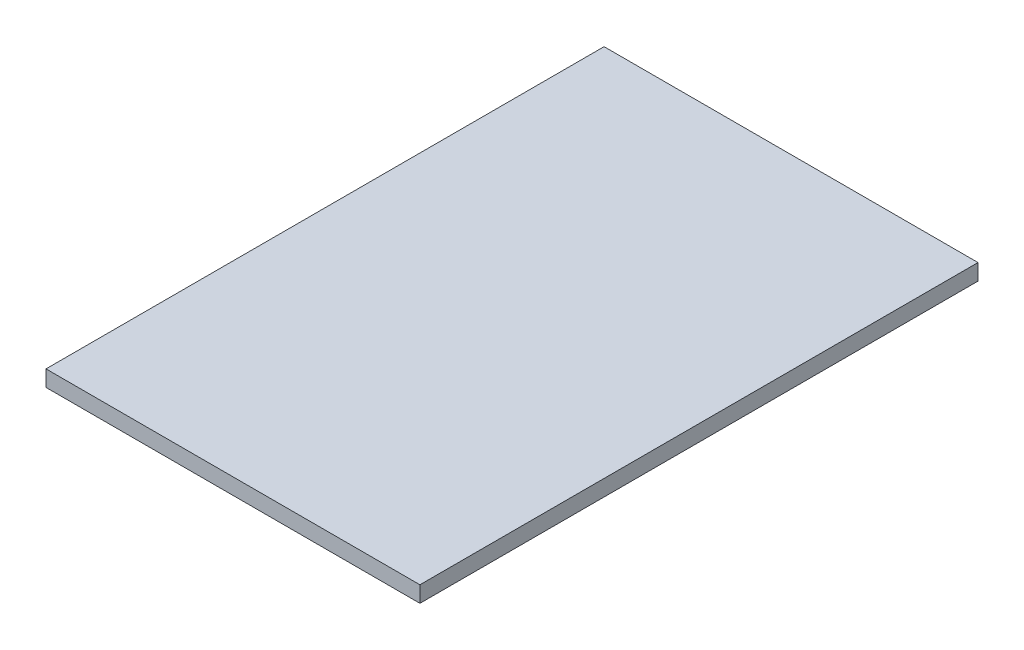
from build123d import *

# Parameters (mm, degrees)
SKETCH1_W           = 40.2
SKETCH1_H           = 1.730239725
BOSS_EXTRUDE1_DEPTH = 60


with BuildPart() as part:
    # Sketch1 → Boss-Extrude1 (new body)
    with BuildSketch(Plane.XY):
        with Locations((-50.070710678, -1.934880138)):
            Rectangle(SKETCH1_W, SKETCH1_H)
    extrude(amount=BOSS_EXTRUDE1_DEPTH)


solid = part.part
